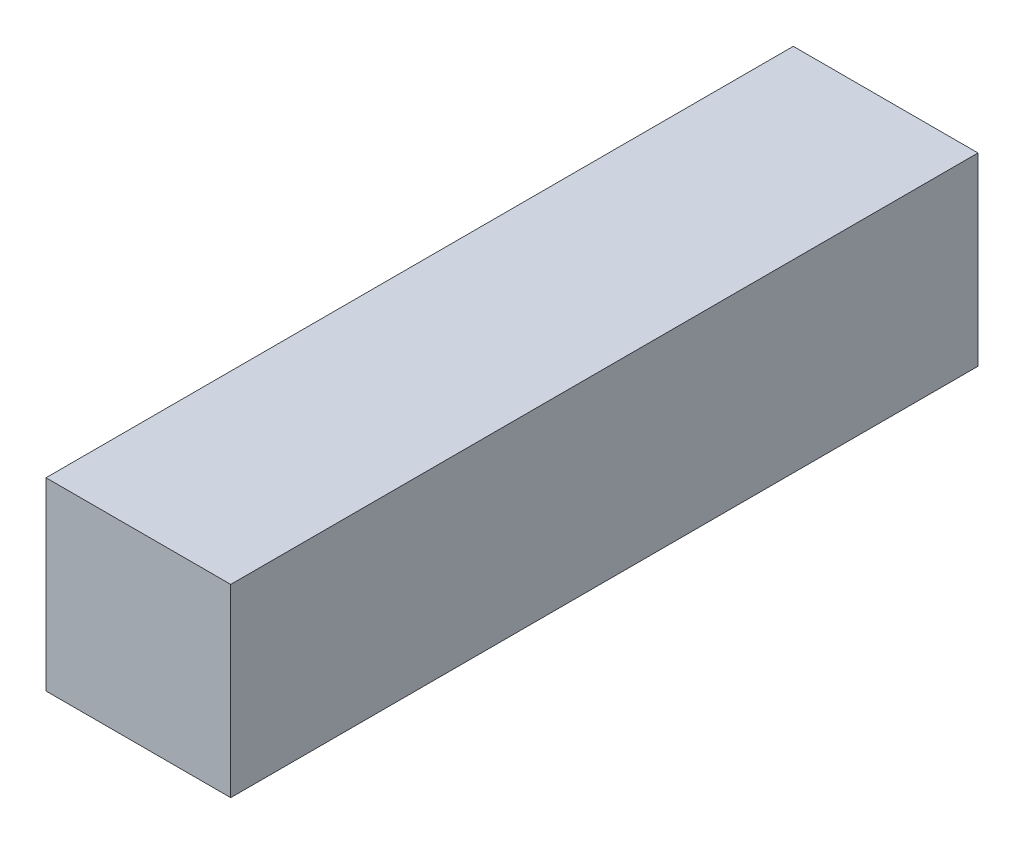
from build123d import *

# Parameters (mm, degrees)
ESQUISSE1_W      = 22
ESQUISSE1_H      = 22
EXTRUSION1_DEPTH = 89


with BuildPart() as part:
    # Esquisse1 → Extrusion1 (new body)
    with BuildSketch(Plane.XY):
        with Locations((11, 11)):
            Rectangle(ESQUISSE1_W, ESQUISSE1_H)
    extrude(amount=-EXTRUSION1_DEPTH)


solid = part.part
